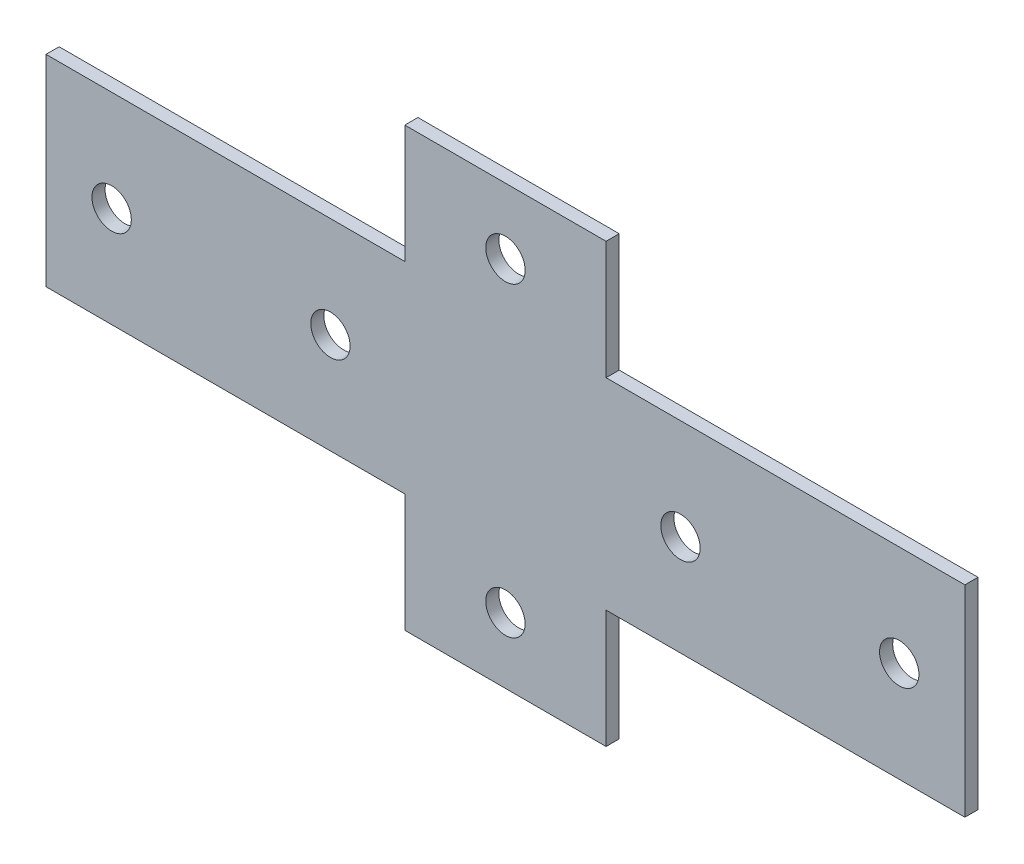
from build123d import *

# Parameters (mm, degrees)
SKETCH_1_R      = 4.5
EXTRUDE_1_DEPTH = 3


with BuildPart() as part:
    # Эскиз1 → Бобышка-Вытянуть1 (new body)
    with BuildSketch(Plane.XY):
        Polygon((23, -23), (105, -23), (105, 23), (23, 23), (23, 50), (-23, 50), (-23, 23), (-105, 23), (-105, -23), (-23, -23), (-23, -50), (23, -50), align=None)
        with Locations((0, 35)):
            Circle(SKETCH_1_R, mode=Mode.SUBTRACT)
        with Locations((0, -35)):
            Circle(SKETCH_1_R, mode=Mode.SUBTRACT)
        with Locations((-90, 0)):
            Circle(SKETCH_1_R, mode=Mode.SUBTRACT)
        with Locations((-40, 0)):
            Circle(SKETCH_1_R, mode=Mode.SUBTRACT)
        with Locations(Location((40, 0, 0), (0, 0, 180))):  # turned: the seam where the file's is
            Circle(SKETCH_1_R, mode=Mode.SUBTRACT)
        with Locations(Location((90, 0, 0), (0, 0, 180))):  # turned: the seam where the file's is
            Circle(SKETCH_1_R, mode=Mode.SUBTRACT)
    extrude(amount=EXTRUDE_1_DEPTH)


solid = part.part
